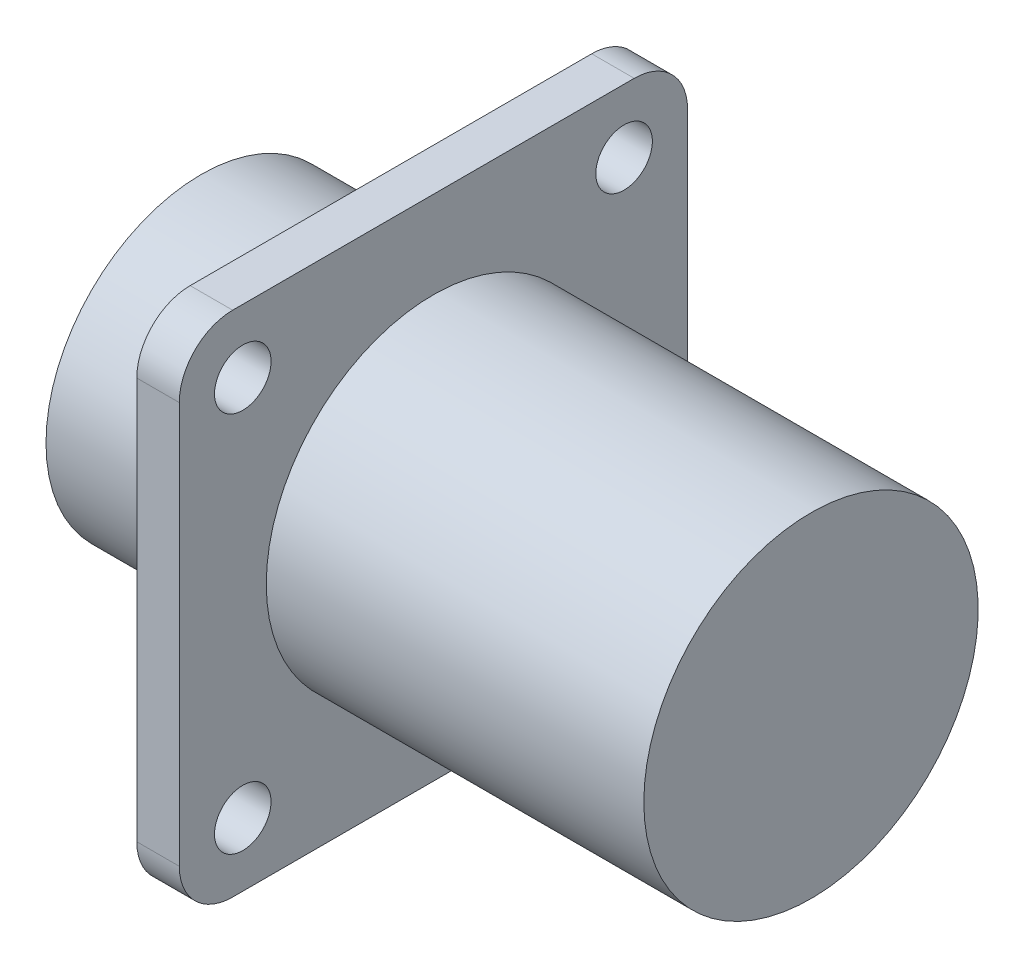
from build123d import *

# Parameters (mm, degrees)
SKETCH2_OUTSIDE_W  = 80.304
SKETCH2_OUTSIDE_H  = 80.304
SKETCH2_OUTSIDE_R  = 1.59
CUT_EXTRUDE1_DEPTH = 24.62


with BuildPart() as part:
    # Sketch1 → Revolve1 (revolve)
    with BuildSketch(Plane.XY, mode=Mode.PRIVATE) as revolve1_sk:
        Polygon((0, 0), (0, 8.725), (10.67, 8.725), (10.67, 30), (13.06, 30), (13.06, 9.4), (34.29, 9.4), (34.29, 0), align=None)
    revolve(revolve1_sk.sketch.rotate(Axis((0, 0, 0), (1, 0, 0)), 90), axis=Axis((0, 0, 0), (1, 0, 0)))  # turned: the seam where the file's is

    # Sketch2 outside → Cut-Extrude1 (cut, through all)
    with BuildSketch(Plane.ZY.offset(-10.67)):
        Rectangle(SKETCH2_OUTSIDE_W, SKETCH2_OUTSIDE_H)
        with BuildLine():
            Line((-11.29, 14.29), (11.29, 14.29))
            ThreePointArc((11.29, 14.29), (13.411320344, 13.411320344), (14.29, 11.29))
            Line((14.29, 11.29), (14.29, -11.29))
            ThreePointArc((14.29, -11.29), (13.411320344, -13.411320344), (11.29, -14.29))
            Line((11.29, -14.29), (-11.29, -14.29))
            ThreePointArc((-11.29, -14.29), (-13.411320344, -13.411320344), (-14.29, -11.29))
            Line((-14.29, -11.29), (-14.29, 11.29))
            ThreePointArc((-14.29, 11.29), (-13.411320344, 13.411320344), (-11.29, 14.29))
        make_face(mode=Mode.SUBTRACT)
        with Locations((10.72, 10.72)):
            Circle(SKETCH2_OUTSIDE_R)
        with Locations((-10.72, 10.72)):
            Circle(SKETCH2_OUTSIDE_R)
        with Locations((-10.72, -10.72)):
            Circle(SKETCH2_OUTSIDE_R)
        with Locations((10.72, -10.72)):
            Circle(SKETCH2_OUTSIDE_R)
    extrude(amount=-CUT_EXTRUDE1_DEPTH, mode=Mode.SUBTRACT)


solid = part.part
